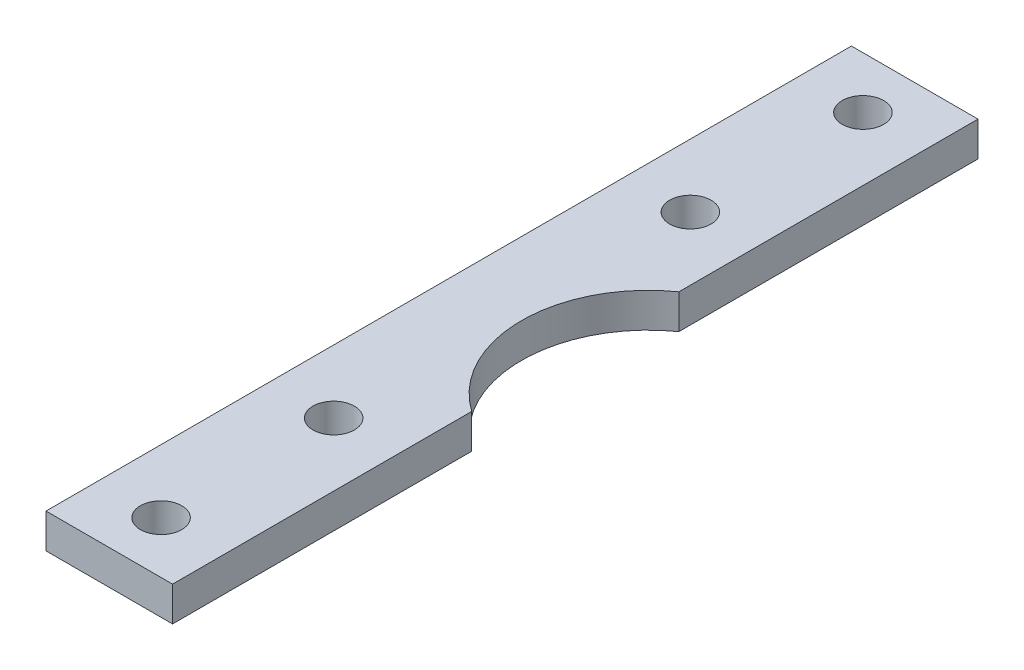
from build123d import *

# Parameters (mm, degrees)
SKETCH1_R           = 1.8
BOSS_EXTRUDE1_DEPTH = 3


with BuildPart() as part:
    # Sketch1 → Boss-Extrude1 (new body)
    with BuildSketch(Plane(origin=(0, 0, 0), x_dir=(1, 0, 0), z_dir=(0, 1, 0))):
        with BuildLine():
            Line((11, 44), (11, 70))
            Line((11, 70), (0, 70))
            Line((0, 70), (0, 0))
            Line((0, 0), (11, 0))
            Line((11, 0), (11, 26))
            ThreePointArc((11, 26), (6.32455532, 35), (11, 44))
        make_face()
        with Locations((5.5, 65.5)):
            Circle(SKETCH1_R, mode=Mode.SUBTRACT)
        with Locations((5.5, 4.5)):
            Circle(SKETCH1_R, mode=Mode.SUBTRACT)
        with Locations((5.5, 19.5)):
            Circle(SKETCH1_R, mode=Mode.SUBTRACT)
        with Locations((5.5, 50.5)):
            Circle(SKETCH1_R, mode=Mode.SUBTRACT)
    extrude(amount=BOSS_EXTRUDE1_DEPTH)


solid = part.part
